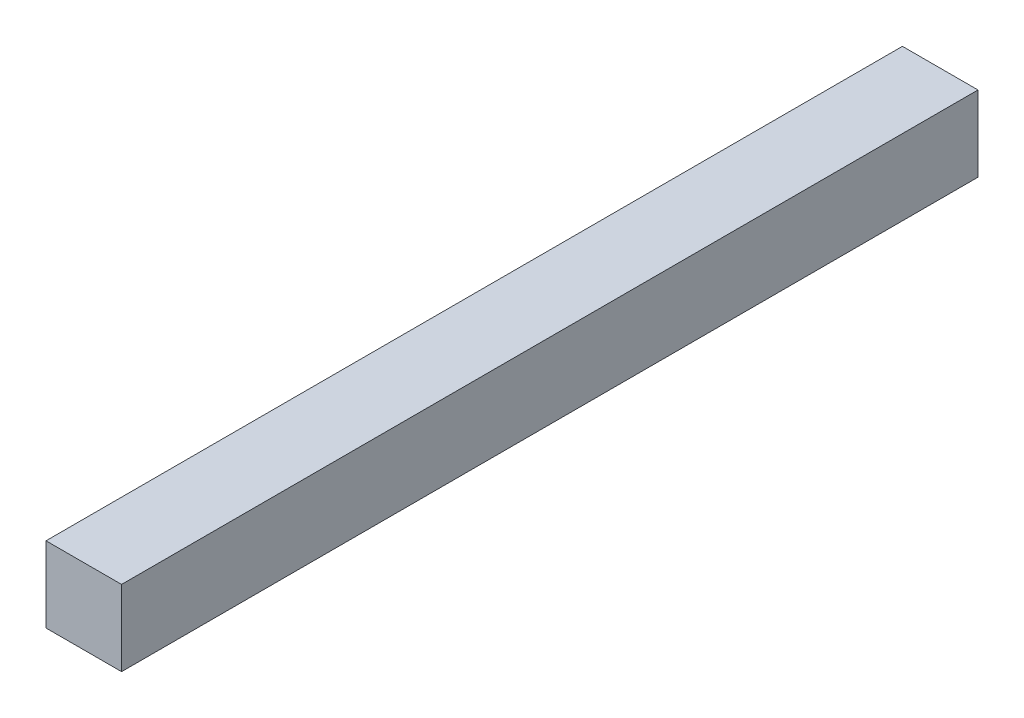
from build123d import *

# Parameters (mm, degrees)
ESQUISSE1_W        = 15
ESQUISSE1_H        = 15
BOSS_EXTRU_1_DEPTH = 170


with BuildPart() as part:
    # Esquisse1 → Boss.-Extru.1 (new body)
    with BuildSketch(Plane.XY):
        Rectangle(ESQUISSE1_W, ESQUISSE1_H)
    extrude(amount=BOSS_EXTRU_1_DEPTH)


solid = part.part
